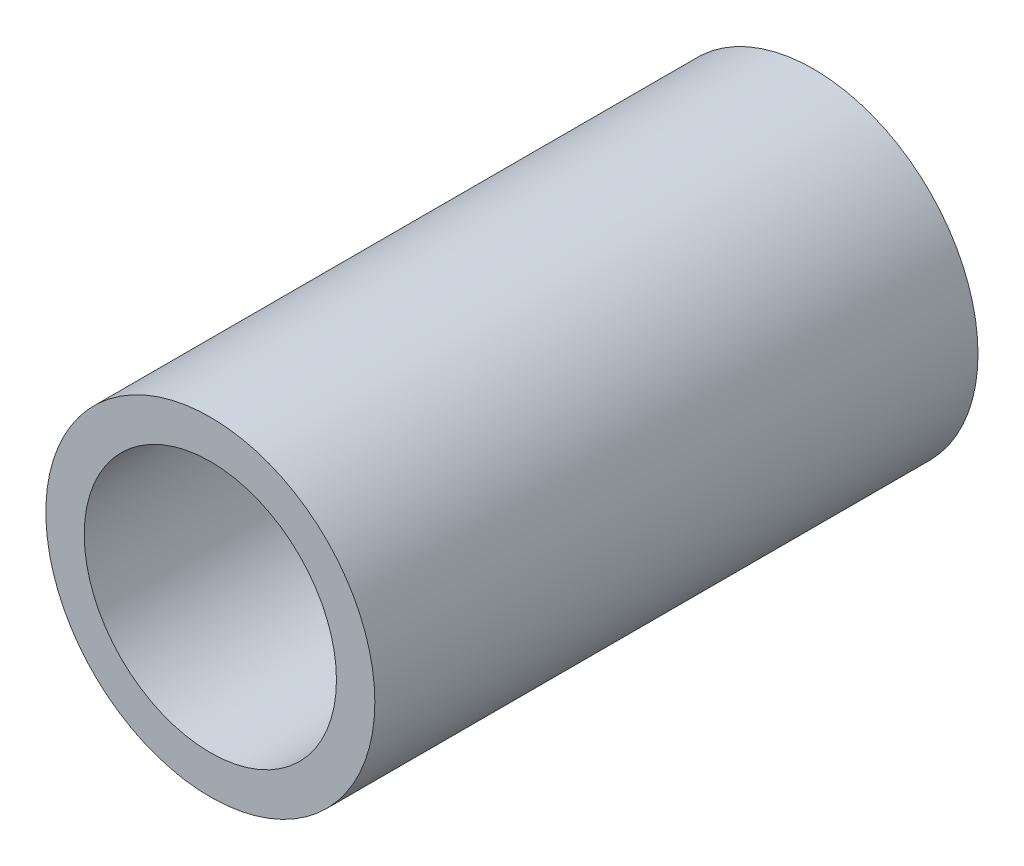
from build123d import *

# Parameters (mm, degrees)
SKETCH5_R           = 30
SKETCH5_R_2         = 23
BOSS_EXTRUDE1_DEPTH = 110


with BuildPart() as part:
    # Sketch5 → Boss-Extrude1 (new body)
    with BuildSketch(Plane.XY):
        Circle(SKETCH5_R)
        Circle(SKETCH5_R_2, mode=Mode.SUBTRACT)
    extrude(amount=BOSS_EXTRUDE1_DEPTH)


solid = part.part
